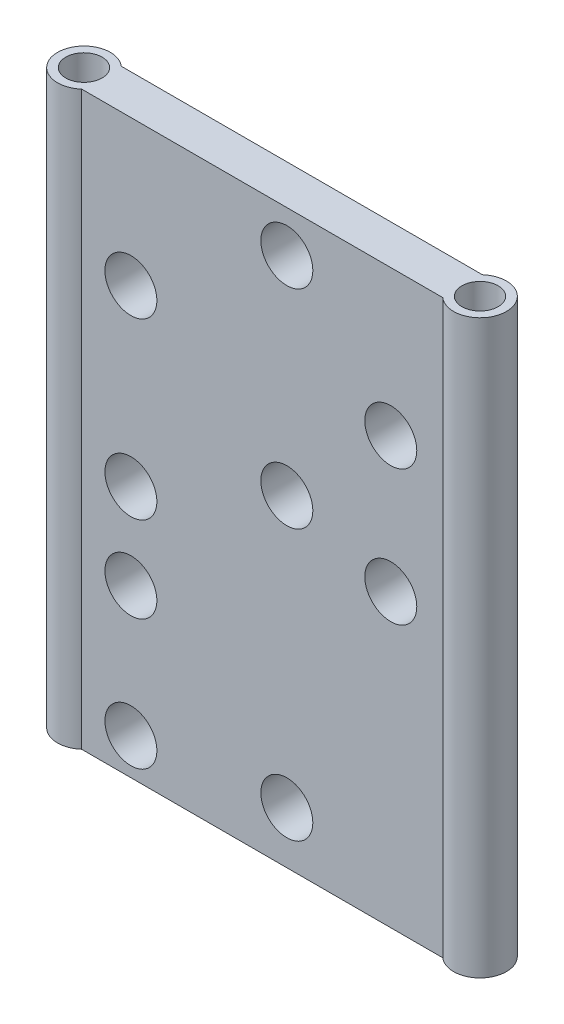
from build123d import *

# Parameters (mm, degrees)
BOSS_EXTRUDE1_DEPTH = 55
SKETCH5_R           = 5
CUT_EXTRUDE2_DEPTH  = 9.89


with BuildPart() as part:
    # Sketch1 → Boss-Extrude1 (new body, symmetric)
    with BuildSketch(Plane(origin=(0, 0, 0), x_dir=(1, 0, 0), z_dir=(0, 1, 0))):
        with BuildLine():
            Line((-38.1, -3.4925), (-38.1, -3.81))
            Line((-38.1, -3.81), (-34.739896, -3.81))
            ThreePointArc((-34.739896, -3.81), (-33.469896, -2.090104), (-33.02, 0))
            ThreePointArc((-33.02, 0), (-33.469896, 2.090104), (-34.739896, 3.81))
            Line((-34.739896, 3.81), (-38.1, 3.81))
            Line((-38.1, 3.81), (-38.1, 3.4925))
            ThreePointArc((-38.1, 3.4925), (-35.63043, 2.46957), (-34.6075, 0))
            ThreePointArc((-34.6075, 0), (-35.63043, -2.46957), (-38.1, -3.4925))
        make_face()
        with BuildLine():
            Line((-34.739896, -3.81), (-38.1, -3.81))
            Line((-38.1, -3.81), (-38.1, -3.4925))
            ThreePointArc((-38.1, -3.4925), (-41.5925, 0), (-38.1, 3.4925))
            Line((-38.1, 3.4925), (-38.1, 3.81))
            Line((-38.1, 3.81), (-34.739896, 3.81))
            ThreePointArc((-34.739896, 3.81), (-43.18, 0), (-34.739896, -3.81))
        make_face()
        with BuildLine():
            ThreePointArc((-33.02, 0), (-33.469896, -2.090104), (-34.739896, -3.81))
            Line((-34.739896, -3.81), (34.739896, -3.81))
            ThreePointArc((34.739896, -3.81), (33.02, 0), (34.739896, 3.81))
            Line((34.739896, 3.81), (-34.739896, 3.81))
            ThreePointArc((-34.739896, 3.81), (-33.469896, 2.090104), (-33.02, 0))
        make_face()
        with BuildLine():
            ThreePointArc((34.739896, 3.81), (33.02, 0), (34.739896, -3.81))
            Line((34.739896, -3.81), (38.1, -3.81))
            Line((38.1, -3.81), (38.1, -3.4925))
            ThreePointArc((38.1, -3.4925), (34.6075, 0), (38.1, 3.4925))
            Line((38.1, 3.4925), (38.1, 3.81))
            Line((38.1, 3.81), (34.739896, 3.81))
        make_face()
        with BuildLine():
            Line((38.1, -3.81), (34.739896, -3.81))
            ThreePointArc((34.739896, -3.81), (40.190104, -4.630104), (43.18, 0))
            ThreePointArc((43.18, 0), (40.190104, 4.630104), (34.739896, 3.81))
            Line((34.739896, 3.81), (38.1, 3.81))
            Line((38.1, 3.81), (38.1, 3.4925))
            ThreePointArc((38.1, 3.4925), (40.56957, 2.46957), (41.5925, 0))
            ThreePointArc((41.5925, 0), (40.56957, -2.46957), (38.1, -3.4925))
            Line((38.1, -3.4925), (38.1, -3.81))
        make_face()
    extrude(amount=BOSS_EXTRUDE1_DEPTH, both=True)

    # Sketch5 → Cut-Extrude2 (cut, through all)
    with BuildSketch(Plane.XY.offset(3.81)):
        with Locations((-25.260104, -48)):
            Circle(SKETCH5_R)
        with Locations((-25.260104, -23)):
            Circle(SKETCH5_R)
        with Locations((4.739896, 47)):
            Circle(SKETCH5_R)
        with Locations((4.739896, -45)):
            Circle(SKETCH5_R)
        with Locations((24.739896, 1)):
            Circle(SKETCH5_R)
        with Locations((-25.260104, 27)):
            Circle(SKETCH5_R)
        with Locations((24.739896, 27)):
            Circle(SKETCH5_R)
        with Locations((-25.260104, -6.5)):
            Circle(SKETCH5_R)
        with Locations((4.739896, 7)):
            Circle(SKETCH5_R)
    extrude(amount=-CUT_EXTRUDE2_DEPTH, mode=Mode.SUBTRACT)


solid = part.part
